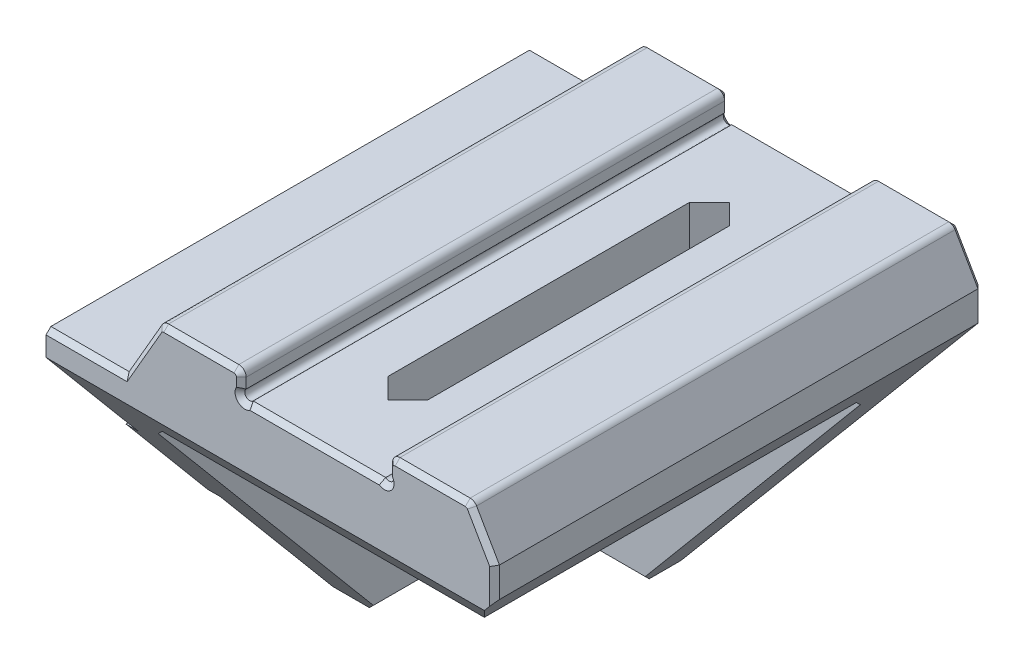
from build123d import *

# Parameters (mm, degrees)
BOSS_EXTRUDE1_DEPTH = 40
CUT_EXTRUDE1_DEPTH  = 35
CUT_EXTRUDE2_DEPTH  = 38.586751346
BOSS_EXTRUDE2_DEPTH = 1
SKETCH5_R           = 1.6
CUT_EXTRUDE3_DEPTH  = 39.586751346
CHAMFER2_SIZE       = 1.3
CHAMFER2_SIZE2      = 1.671247785
FILLET1_R           = 0.6
CUT_EXTRUDE4_DEPTH  = 34
SKETCH7_W           = 8
SKETCH7_H           = 31
CUT_EXTRUDE5_DEPTH  = 3
CHAMFER3_SIZE       = 2
CHAMFER4_SIZE       = 0.4


with BuildPart() as part:
    # Sketch1 → Boss-Extrude1 (new body)
    with BuildSketch(Plane.XY):
        with BuildLine():
            Line((0, 0), (0, -30))
            Line((0, -30), (12.413762411, -30))
            Line((12.413762411, -30), (37.586751346, 0))
            Line((37.586751346, 0), (34.7, 5))
            Line((34.7, 5), (28, 5))
            Line((28, 5), (28, 3.565685425))
            ThreePointArc((28, 3.565685425), (28, 3), (27.434314575, 3))
            Line((27.434314575, 3), (16.573996535, 3))
            ThreePointArc((16.573996535, 3), (16.008373082, 2.991626918), (16, 3.557250372))
            Line((16, 3.557250372), (16, 5))
            Line((16, 5), (9.3, 5))
            Line((9.3, 5), (6.413248654, 0))
            Line((6.413248654, 0), (0, 0))
        make_face()
    extrude(amount=BOSS_EXTRUDE1_DEPTH)

    # Sketch2 → Cut-Extrude1 (cut)
    with BuildSketch(Plane.XY.offset(40)):
        Polygon((5, -5), (5, -30), (12.413762411, -30), (33.39125319, -5), align=None)
    extrude(amount=-CUT_EXTRUDE1_DEPTH, mode=Mode.SUBTRACT)

    # Sketch3 → Cut-Extrude2 (cut, through all)
    with BuildSketch(Plane.ZY):
        Polygon((40, -30), (40, -2), (16.505210327, -30), align=None)
    extrude(amount=-CUT_EXTRUDE2_DEPTH, mode=Mode.SUBTRACT)

    # Sketch4 → Boss-Extrude2 (add)
    with BuildSketch(Plane.ZY):
        Polygon((0, -11), (0, -19), (25.73530627, -19), (32.448103319, -11), align=None)
    extrude(amount=BOSS_EXTRUDE2_DEPTH)

    # Sketch5 → Cut-Extrude3 (cut, through all)
    with BuildSketch(Plane.ZY.offset(1)):
        with Locations((14.545852397, -15)):
            Circle(SKETCH5_R)
    extrude(amount=-CUT_EXTRUDE3_DEPTH, mode=Mode.SUBTRACT)

    # Chamfer2
    chamfer2_edges = [part.edges().sort_by_distance(p)[0] for p in [
        (37.586751346, 0, 20),
    ]]
    chamfer2_side = [part.faces().sort_by_distance(p)[0] for p in [
        (25.000256878, -15, 0.559792763),
    ]]
    chamfer(chamfer2_edges, length=CHAMFER2_SIZE, length2=CHAMFER2_SIZE2, reference=chamfer2_side[0])

    # Fillet1
    fillet1_edges = [part.edges().sort_by_distance(p)[0] for p in [
        (9.3, 5, 20),
        (16, 5, 20),
        (28, 5, 20),
        (34.7, 5, 20),
    ]]
    fillet(fillet1_edges, radius=FILLET1_R)

    # Sketch6 → Cut-Extrude4 (cut, through all)
    with BuildSketch(Plane(origin=(0, 3, 0), x_dir=(1, 0, 0), z_dir=(0, 1, 0))):
        Polygon((22.004155555, -6), (20.354155555, -7.65), (20.354155555, -32.35), (22.004155555, -34), (23.654155555, -32.35), (23.654155555, -7.65), align=None)
    extrude(amount=-CUT_EXTRUDE4_DEPTH, mode=Mode.SUBTRACT)

    # Sketch7 → Cut-Extrude5 (cut)
    with BuildSketch(Plane.XZ.offset(5)):
        with Locations((22.004155555, 20.5)):
            Rectangle(SKETCH7_W, SKETCH7_H)
    extrude(amount=-CUT_EXTRUDE5_DEPTH, mode=Mode.SUBTRACT)

    # Chamfer3
    chamfer3_edges = [part.edges().sort_by_distance(p)[0] for p in [
        (29.697704373, -5, 5),
        (5, -5, 21.241350553),
        (8.706881205, -30, 5),
        (5, -30, 10.752605164),
        (11.502077778, -5, 5),
        (5, -17.5, 5),
    ]]
    chamfer(chamfer3_edges, length=CHAMFER3_SIZE)

    # Chamfer4
    chamfer4_edges = [part.edges().sort_by_distance(p)[0] for p in [
        (31.476794919, 5, 0),
        (31.476794919, 5, 40),
        (7.770021787, 2.35, 0),
        (12.523205081, 5, 0),
        (28, 3.982842712, 0),
        (28.175735931, 4.824264069, 0),
        (9.346410162, 4.919615242, 0),
        (15.824264069, 4.824264069, 0),
        (34.653589838, 4.919615242, 0),
        (28, 3.982842712, 40),
        (12.523205081, 5, 40),
        (7.770021787, 2.35, 40),
        (28.175735931, 4.824264069, 40),
        (9.346410162, 4.919615242, 40),
        (15.824264069, 4.824264069, 40),
        (34.653589838, 4.919615242, 40),
        (16, 3.978625186, 0),
        (16.008373082, 2.991626918, 0),
        (22.004155555, 3, 0),
        (28, 3, 0),
        (24.582444932, -15.497928888, 0),
        (6.206881205, -30, 0),
        (0, -5.5, 0),
        (3.206624327, 0, 0),
        (28, 3, 40),
        (22.004155555, 3, 40),
        (16.008373082, 2.991626918, 40),
        (16, 3.978625186, 40),
        (3.206624327, 0, 40),
        (0, -24.5, 0),
        (-0.5, -11, 0),
        (-0.5, -19, 0),
        (-1, -15, 0),
        (35.812166267, 3.073671519, 0),
        (35.812166267, 3.073671519, 40),
        (36.751127453, 0.225742631, 0),
        (36.751127453, 0.225742631, 40),
    ]]
    chamfer(chamfer4_edges, length=CHAMFER4_SIZE)


solid = part.part
